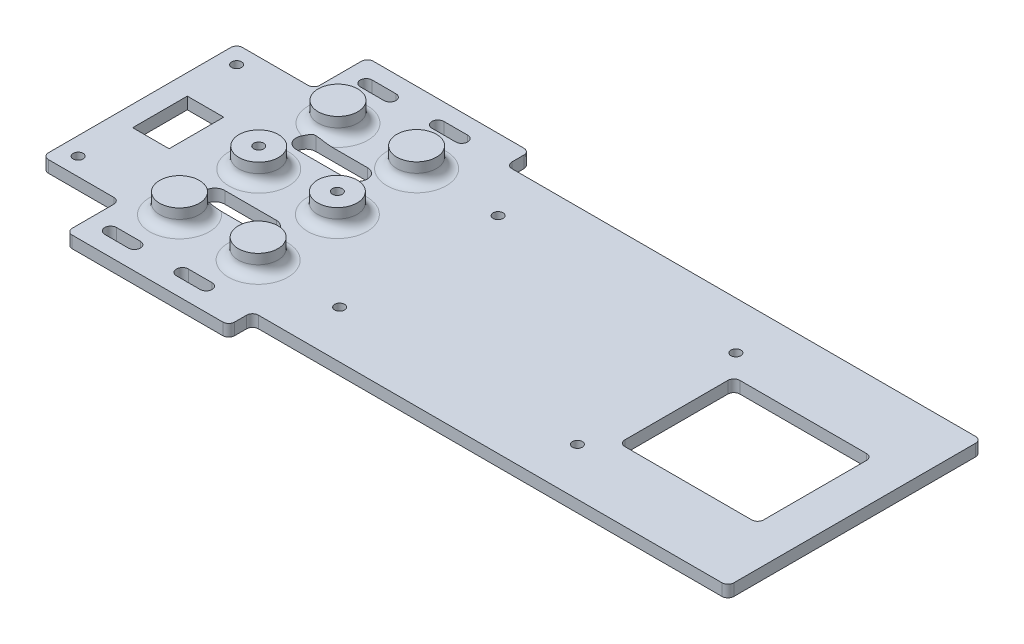
from build123d import *

# Parameters (mm, degrees)
SKETCH1_R           = 1.25
BOSS_EXTRUDE1_DEPTH = 3
SKETCH2_R           = 5
BOSS_EXTRUDE2_DEPTH = 5
FILLET1_R           = 2.5
SKETCH3_R           = 1.25
SKETCH3_W           = 9.2
SKETCH3_H           = 13.8
SKETCH3_W_2         = 35
SKETCH3_H_2         = 29
CUT_EXTRUDE1_DEPTH  = 9
FILLET2_R           = 1.5


with BuildPart() as part:
    # Sketch1 → Boss-Extrude1 (new body)
    with BuildSketch(Plane(origin=(0, 0, 0), x_dir=(1, 0, 0), z_dir=(0, 1, 0))):
        Polygon((-20.5, -38), (20.5, -38), (20.5, -32), (140.5, -32), (140.5, 32), (20.5, 32), (20.5, 38), (-20.5, 38), (-20.5, 24.5), (-40, 24.5), (-40, -24.5), (-20.5, -24.5), align=None)
        with Locations((-35.5, 20)):
            Circle(SKETCH1_R, mode=Mode.SUBTRACT)
        with Locations((-35.5, -20)):
            Circle(SKETCH1_R, mode=Mode.SUBTRACT)
    extrude(amount=BOSS_EXTRUDE1_DEPTH)

    # Sketch2 → Boss-Extrude2 (add)
    with BuildSketch(Plane(origin=(0, 3, 0), x_dir=(1, 0, 0), z_dir=(0, 1, 0))):
        with Locations((-9.925, 20)):
            Circle(SKETCH2_R)
        with Locations((9.925, 20)):
            Circle(SKETCH2_R)
        with Locations((-9.925, 0)):
            Circle(SKETCH2_R)
        with Locations((9.925, 0)):
            Circle(SKETCH2_R)
        with Locations((9.925, -20)):
            Circle(SKETCH2_R)
        with Locations((-9.925, -20)):
            Circle(SKETCH2_R)
    extrude(amount=BOSS_EXTRUDE2_DEPTH)

    # Fillet1
    fillet1_edges = [part.edges().sort_by_distance(p)[0] for p in [
        (-14.925, 3, -20),
        (4.925, 3, -20),
        (-14.925, 3, 0),
        (4.925, 3, 0),
        (4.925, 3, 20),
        (-14.925, 3, 20),
    ]]
    fillet(fillet1_edges, radius=FILLET1_R)

    # Sketch3 → Cut-Extrude1 (cut, through all)
    with BuildSketch(Plane(origin=(0, 0, 0), x_dir=(-1, 0, 0), z_dir=(0, -1, 0))):
        with BuildLine():
            Line((3.5, -14), (9.5, -14))
            ThreePointArc((9.5, -14), (12, -11.5), (9.5, -9))
            Line((9.5, -9), (3.5, -9))
            ThreePointArc((3.5, -9), (6, -11.5), (3.5, -14))
        make_face()
        with BuildLine():
            Line((3.5, -9), (-3.5, -9))
            ThreePointArc((-3.5, -9), (-6, -11.5), (-3.5, -14))
            Line((-3.5, -14), (3.5, -14))
            ThreePointArc((3.5, -14), (6, -11.5), (3.5, -9))
        make_face()
        with BuildLine():
            Line((3.5, 9), (9.5, 9))
            ThreePointArc((9.5, 9), (12, 11.5), (9.5, 14))
            Line((9.5, 14), (3.5, 14))
            ThreePointArc((3.5, 14), (6, 11.5), (3.5, 9))
        make_face()
        with BuildLine():
            Line((3.5, 14), (-3.5, 14))
            ThreePointArc((-3.5, 14), (-6, 11.5), (-3.5, 9))
            Line((-3.5, 9), (3.5, 9))
            ThreePointArc((3.5, 9), (6, 11.5), (3.5, 14))
        make_face()
        with BuildLine():
            Line((9.05, -33.75), (15.05, -33.75))
            ThreePointArc((15.05, -33.75), (16.55, -32.25), (15.05, -30.75))
            Line((15.05, -30.75), (9.05, -30.75))
            ThreePointArc((9.05, -30.75), (7.55, -32.25), (9.05, -33.75))
        make_face()
        with BuildLine():
            Line((-3.05, -30.75), (-9.05, -30.75))
            ThreePointArc((-9.05, -30.75), (-10.55, -32.25), (-9.05, -33.75))
            Line((-9.05, -33.75), (-3.05, -33.75))
            ThreePointArc((-3.05, -33.75), (-1.55, -32.25), (-3.05, -30.75))
        make_face()
        with BuildLine():
            Line((-9.05, 30.75), (-3.05, 30.75))
            ThreePointArc((-3.05, 30.75), (-1.55, 32.25), (-3.05, 33.75))
            Line((-3.05, 33.75), (-9.05, 33.75))
            ThreePointArc((-9.05, 33.75), (-10.55, 32.25), (-9.05, 30.75))
        make_face()
        with Locations((-30.5, 20)):
            Circle(SKETCH3_R)
        with Locations((-30.5, -20)):
            Circle(SKETCH3_R)
        with Locations((-90.5, -20)):
            Circle(SKETCH3_R)
        with Locations((-90.5, 20)):
            Circle(SKETCH3_R)
        with BuildLine():
            ThreePointArc((9.05, 33.75), (7.55, 32.25), (9.05, 30.75))
            Line((9.05, 30.75), (15.05, 30.75))
            ThreePointArc((15.05, 30.75), (16.55, 32.25), (15.05, 33.75))
            Line((15.05, 33.75), (9.05, 33.75))
        make_face()
        with Locations((30.25, 0)):
            Rectangle(SKETCH3_W, SKETCH3_H)
        with Locations((-113, 0)):
            Rectangle(SKETCH3_W_2, SKETCH3_H_2)
        with Locations((9.925, 0)):
            Circle(SKETCH3_R)
        with Locations((-9.925, 0)):
            Circle(SKETCH3_R)
    extrude(amount=-CUT_EXTRUDE1_DEPTH, mode=Mode.SUBTRACT)

    # Fillet2
    fillet2_edges = [part.edges().sort_by_distance(p)[0] for p in [
        (95.5, 1.5, 14.5),
        (130.5, 1.5, 14.5),
        (130.5, 1.5, -14.5),
        (95.5, 1.5, -14.5),
        (-20.5, 1.5, -38),
        (20.5, 1.5, -38),
        (20.5, 1.5, -32),
        (140.5, 1.5, -32),
        (140.5, 1.5, 32),
        (20.5, 1.5, 32),
        (20.5, 1.5, 38),
        (-20.5, 1.5, 38),
        (-20.5, 1.5, 24.5),
        (-40, 1.5, 24.5),
        (-40, 1.5, -24.5),
        (-20.5, 1.5, -24.5),
    ]]
    fillet(fillet2_edges, radius=FILLET2_R)


solid = part.part
